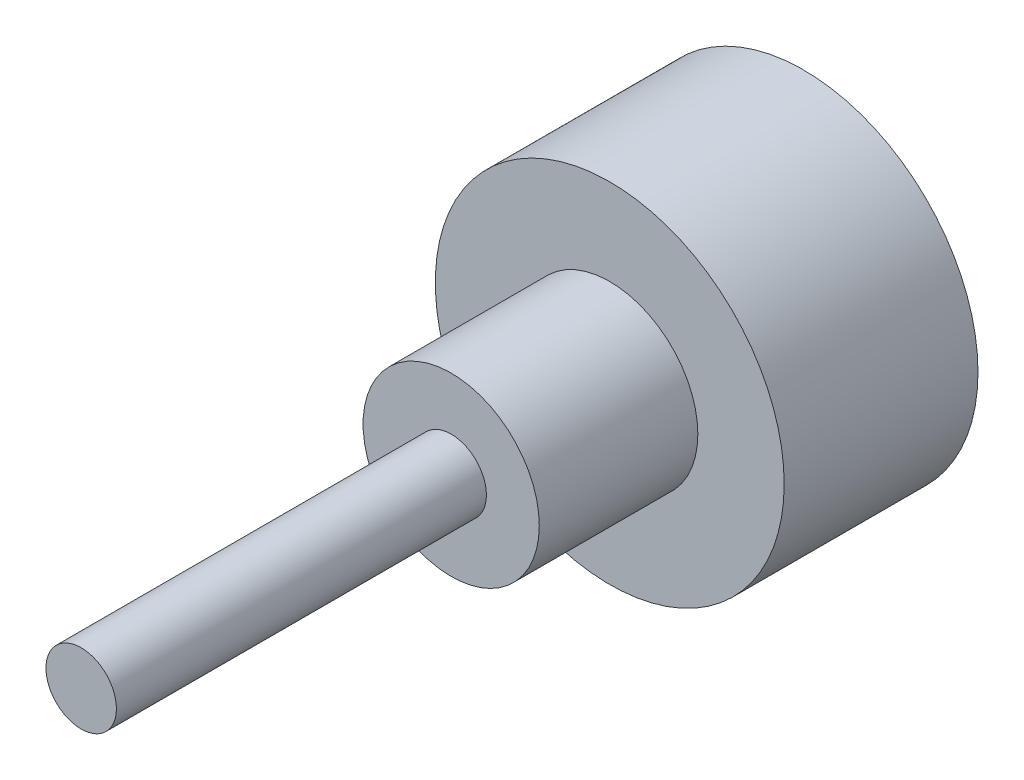
from build123d import *

# Parameters (mm, degrees)
CROQUIS1_R              = 9.9
CROQUIS1_R_2            = 7.9
SALIENTE_EXTRUIR1_DEPTH = 10
CROQUIS2_R              = 9.9
SALIENTE_EXTRUIR2_DEPTH = 1
CROQUIS4_R              = 5
SALIENTE_EXTRUIR4_DEPTH = 9
CROQUIS3_R              = 2
SALIENTE_EXTRUIR3_DEPTH = 30


with BuildPart() as part:
    # Croquis1 → Saliente-Extruir1 (new body)
    with BuildSketch(Plane.XY):
        Circle(CROQUIS1_R)
        Circle(CROQUIS1_R_2, mode=Mode.SUBTRACT)
    extrude(amount=SALIENTE_EXTRUIR1_DEPTH)

    # Croquis2 → Saliente-Extruir2 (add)
    with BuildSketch(Plane.XY.offset(10)):
        Circle(CROQUIS2_R)
    extrude(amount=SALIENTE_EXTRUIR2_DEPTH)

    # Croquis4 → Saliente-Extruir4 (add)
    with BuildSketch(Plane.XY.offset(11)):
        Circle(CROQUIS4_R)
    extrude(amount=SALIENTE_EXTRUIR4_DEPTH)

    # Croquis3 → Saliente-Extruir3 (add)
    with BuildSketch(Plane.XY.offset(11)):
        Circle(CROQUIS3_R)
    extrude(amount=SALIENTE_EXTRUIR3_DEPTH)


solid = part.part
